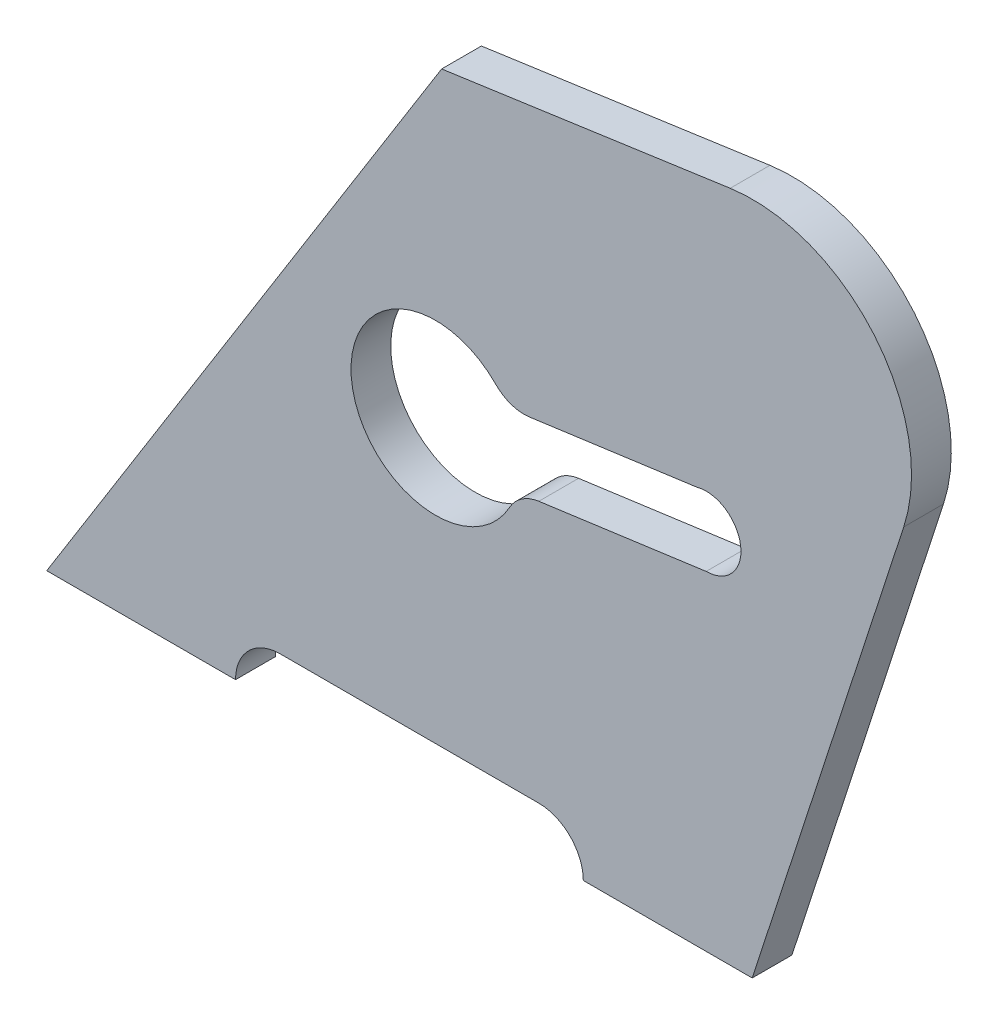
from build123d import *

# Parameters (mm, degrees)
BOSS_EXTRUDE1_DEPTH = 8


with BuildPart() as part:
    # Sketch1 → Boss-Extrude1 (new body)
    with BuildSketch(Plane.XY):
        with BuildLine():
            Line((79.487889635, 127.207214423), (0, 0))
            Line((0, 0), (38, 0))
            ThreePointArc((38, 0), (40.636038969, 6.363961031), (47, 9))
            Line((47, 9), (99, 9))
            ThreePointArc((99, 9), (105.363961031, 6.363961031), (108, 0))
            Line((108, 0), (142, 0))
            Line((142, 0), (172.50354814, 93.880267937))
            ThreePointArc((172.50354814, 93.880267937), (166.569139078, 124.354715336), (137.573015724, 135.451290736))
            Line((137.573015724, 135.451290736), (79.487889635, 127.207214423))
        make_face()
        with BuildLine():
            ThreePointArc((130.852326035, 79.986711388), (131.785075785, 80.179945877), (132.735423682, 80.244757424))
            ThreePointArc((132.735423682, 80.244757424), (139.670612135, 74.195105322), (134.61852133, 66.50280346))
            ThreePointArc((134.61852133, 66.50280346), (133.68577158, 66.309568971), (132.735423682, 66.244757424))
            Line((132.735423682, 66.244757424), (99.049026675, 61.628618036))
            ThreePointArc((99.049026675, 61.628618036), (95.608426443, 60.298814317), (93.130184546, 57.566704329))
            ThreePointArc((93.130184546, 57.566704329), (61.402056741, 63.469750476), (90.372565984, 77.690497362))
            ThreePointArc((90.372565984, 77.690497362), (93.494426366, 75.725784751), (97.165929028, 75.370572))
            Line((97.165929028, 75.370572), (130.852326035, 79.986711388))
        make_face(mode=Mode.SUBTRACT)
    extrude(amount=BOSS_EXTRUDE1_DEPTH)


solid = part.part
